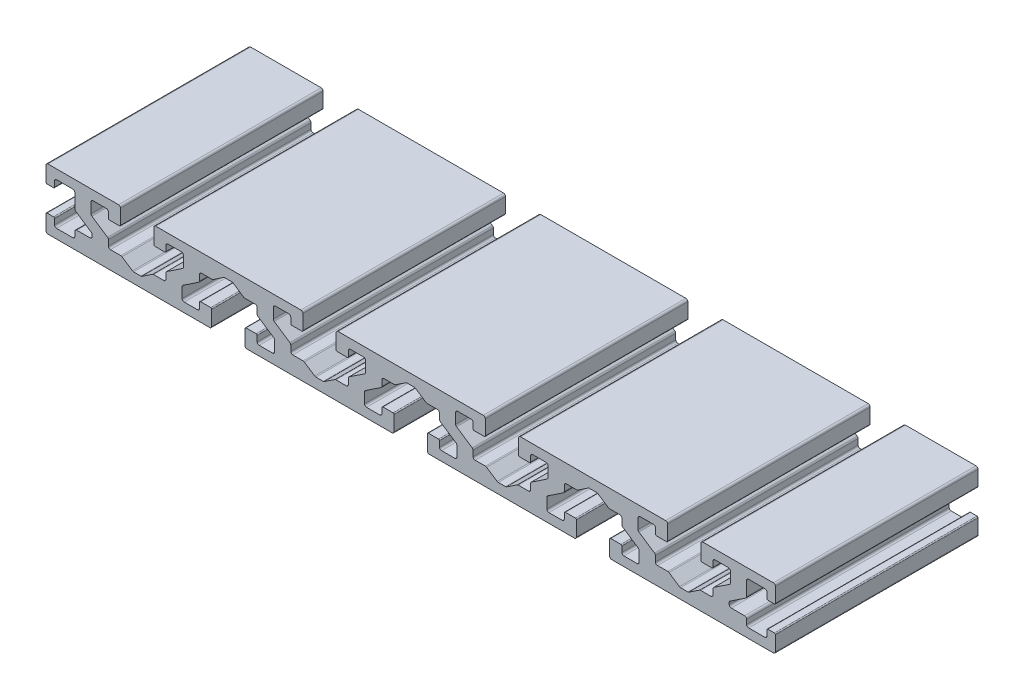
from build123d import *

# Parameters (mm, degrees)
BOSS_EXTRUDE1_DEPTH = 50


with BuildPart() as part:
    # Sketch1 → Boss-Extrude1 (new body)
    with BuildSketch(Plane.XY):
        with BuildLine():
            Line((0.5, 0), (40.4, 0))
            ThreePointArc((40.4, 0), (40.753553391, 0.146446609), (40.9, 0.5))
            Line((40.9, 0.5), (40.9, 4.15))
            ThreePointArc((40.9, 4.15), (40.826776695, 4.326776695), (40.65, 4.4))
            Line((40.65, 4.4), (38.15, 4.4))
            ThreePointArc((38.15, 4.4), (37.973223305, 4.326776695), (37.9, 4.15))
            Line((37.9, 4.15), (37.9, 2.8))
            ThreePointArc((37.9, 2.8), (37.753553391, 2.446446609), (37.4, 2.3))
            Line((37.4, 2.3), (34.1, 2.3))
            ThreePointArc((34.1, 2.3), (33.746446609, 2.446446609), (33.6, 2.8))
            Line((33.6, 2.8), (33.6, 5.329632483))
            ThreePointArc((33.6, 5.329632483), (33.659162701, 5.565561446), (33.822649902, 5.74565763))
            Line((33.822649902, 5.74565763), (37.677350098, 8.315457761))
            ThreePointArc((37.677350098, 8.315457761), (37.840837299, 8.495553945), (37.9, 8.731482908))
            Line((37.9, 8.731482908), (37.9, 10.1))
            ThreePointArc((37.9, 10.1), (38.046446609, 10.453553391), (38.4, 10.6))
            Line((38.4, 10.6), (40.952775638, 10.6))
            ThreePointArc((40.952775638, 10.6), (41.097667712, 10.621453987), (41.230125736, 10.683974853))
            Line((41.230125736, 10.683974853), (43.828201177, 12.416025147))
            ThreePointArc((43.828201177, 12.416025147), (43.960659201, 12.478546013), (44.105551275, 12.5))
            Line((44.105551275, 12.5), (45.894448725, 12.5))
            ThreePointArc((45.894448725, 12.5), (46.039340799, 12.478546013), (46.171798823, 12.416025147))
            Line((46.171798823, 12.416025147), (48.769874264, 10.683974853))
            ThreePointArc((48.769874264, 10.683974853), (48.902332288, 10.621453987), (49.047224362, 10.6))
            Line((49.047224362, 10.6), (51.6, 10.6))
            ThreePointArc((51.6, 10.6), (51.953553391, 10.453553391), (52.1, 10.1))
            Line((52.1, 10.1), (52.1, 8.731482908))
            ThreePointArc((52.1, 8.731482908), (52.159162701, 8.495553945), (52.322649902, 8.315457761))
            Line((52.322649902, 8.315457761), (56.177350098, 5.74565763))
            ThreePointArc((56.177350098, 5.74565763), (56.340837299, 5.565561446), (56.4, 5.329632483))
            Line((56.4, 5.329632483), (56.4, 2.8))
            ThreePointArc((56.4, 2.8), (56.253553391, 2.446446609), (55.9, 2.3))
            Line((55.9, 2.3), (52.6, 2.3))
            ThreePointArc((52.6, 2.3), (52.246446609, 2.446446609), (52.1, 2.8))
            Line((52.1, 2.8), (52.1, 4.15))
            ThreePointArc((52.1, 4.15), (52.026776695, 4.326776695), (51.85, 4.4))
            Line((51.85, 4.4), (49.35, 4.4))
            ThreePointArc((49.35, 4.4), (49.173223305, 4.326776695), (49.1, 4.15))
            Line((49.1, 4.15), (49.1, 0.5))
            ThreePointArc((49.1, 0.5), (49.246446609, 0.146446609), (49.6, 0))
            Line((49.6, 0), (85.4, 0))
            ThreePointArc((85.4, 0), (85.753553391, 0.146446609), (85.9, 0.5))
            Line((85.9, 0.5), (85.9, 4.15))
            ThreePointArc((85.9, 4.15), (85.826776695, 4.326776695), (85.65, 4.4))
            Line((85.65, 4.4), (83.15, 4.4))
            ThreePointArc((83.15, 4.4), (82.973223305, 4.326776695), (82.9, 4.15))
            Line((82.9, 4.15), (82.9, 2.8))
            ThreePointArc((82.9, 2.8), (82.753553391, 2.446446609), (82.4, 2.3))
            Line((82.4, 2.3), (79.1, 2.3))
            ThreePointArc((79.1, 2.3), (78.746446609, 2.446446609), (78.6, 2.8))
            Line((78.6, 2.8), (78.6, 5.329632483))
            ThreePointArc((78.6, 5.329632483), (78.659162701, 5.565561446), (78.822649902, 5.74565763))
            Line((78.822649902, 5.74565763), (82.677350098, 8.315457761))
            ThreePointArc((82.677350098, 8.315457761), (82.840837299, 8.495553945), (82.9, 8.731482908))
            Line((82.9, 8.731482908), (82.9, 10.1))
            ThreePointArc((82.9, 10.1), (83.046446609, 10.453553391), (83.4, 10.6))
            Line((83.4, 10.6), (85.952775638, 10.6))
            ThreePointArc((85.952775638, 10.6), (86.097667712, 10.621453987), (86.230125736, 10.683974853))
            Line((86.230125736, 10.683974853), (88.828201177, 12.416025147))
            ThreePointArc((88.828201177, 12.416025147), (88.960659201, 12.478546013), (89.105551275, 12.5))
            Line((89.105551275, 12.5), (90.894448725, 12.5))
            ThreePointArc((90.894448725, 12.5), (91.039340799, 12.478546013), (91.171798823, 12.416025147))
            Line((91.171798823, 12.416025147), (93.769874264, 10.683974853))
            ThreePointArc((93.769874264, 10.683974853), (93.902332288, 10.621453987), (94.047224362, 10.6))
            Line((94.047224362, 10.6), (96.6, 10.6))
            ThreePointArc((96.6, 10.6), (96.953553391, 10.453553391), (97.1, 10.1))
            Line((97.1, 10.1), (97.1, 8.731482908))
            ThreePointArc((97.1, 8.731482908), (97.159162701, 8.495553945), (97.322649902, 8.315457761))
            Line((97.322649902, 8.315457761), (101.177350098, 5.74565763))
            ThreePointArc((101.177350098, 5.74565763), (101.340837299, 5.565561446), (101.4, 5.329632483))
            Line((101.4, 5.329632483), (101.4, 2.8))
            ThreePointArc((101.4, 2.8), (101.253553391, 2.446446609), (100.9, 2.3))
            Line((100.9, 2.3), (97.6, 2.3))
            ThreePointArc((97.6, 2.3), (97.246446609, 2.446446609), (97.1, 2.8))
            Line((97.1, 2.8), (97.1, 4.15))
            ThreePointArc((97.1, 4.15), (97.026776695, 4.326776695), (96.85, 4.4))
            Line((96.85, 4.4), (94.35, 4.4))
            ThreePointArc((94.35, 4.4), (94.173223305, 4.326776695), (94.1, 4.15))
            Line((94.1, 4.15), (94.1, 0.5))
            ThreePointArc((94.1, 0.5), (94.246446609, 0.146446609), (94.6, 0))
            Line((94.6, 0), (130.4, 0))
            ThreePointArc((130.4, 0), (130.753553391, 0.146446609), (130.9, 0.5))
            Line((130.9, 0.5), (130.9, 4.15))
            ThreePointArc((130.9, 4.15), (130.826776695, 4.326776695), (130.65, 4.4))
            Line((130.65, 4.4), (128.15, 4.4))
            ThreePointArc((128.15, 4.4), (127.973223305, 4.326776695), (127.9, 4.15))
            Line((127.9, 4.15), (127.9, 2.8))
            ThreePointArc((127.9, 2.8), (127.753553391, 2.446446609), (127.4, 2.3))
            Line((127.4, 2.3), (124.1, 2.3))
            ThreePointArc((124.1, 2.3), (123.746446609, 2.446446609), (123.6, 2.8))
            Line((123.6, 2.8), (123.6, 5.329632483))
            ThreePointArc((123.6, 5.329632483), (123.659162701, 5.565561446), (123.822649902, 5.74565763))
            Line((123.822649902, 5.74565763), (127.677350098, 8.315457761))
            ThreePointArc((127.677350098, 8.315457761), (127.840837299, 8.495553945), (127.9, 8.731482908))
            Line((127.9, 8.731482908), (127.9, 10.1))
            ThreePointArc((127.9, 10.1), (128.046446609, 10.453553391), (128.4, 10.6))
            Line((128.4, 10.6), (130.952775638, 10.6))
            ThreePointArc((130.952775638, 10.6), (131.097667712, 10.621453987), (131.230125736, 10.683974853))
            Line((131.230125736, 10.683974853), (133.828201177, 12.416025147))
            ThreePointArc((133.828201177, 12.416025147), (133.960659201, 12.478546013), (134.105551275, 12.5))
            Line((134.105551275, 12.5), (135.894448725, 12.5))
            ThreePointArc((135.894448725, 12.5), (136.039340799, 12.478546013), (136.171798823, 12.416025147))
            Line((136.171798823, 12.416025147), (138.769874264, 10.683974853))
            ThreePointArc((138.769874264, 10.683974853), (138.902332288, 10.621453987), (139.047224362, 10.6))
            Line((139.047224362, 10.6), (141.6, 10.6))
            ThreePointArc((141.6, 10.6), (141.953553391, 10.453553391), (142.1, 10.1))
            Line((142.1, 10.1), (142.1, 8.731482908))
            ThreePointArc((142.1, 8.731482908), (142.159162701, 8.495553945), (142.322649902, 8.315457761))
            Line((142.322649902, 8.315457761), (146.177350098, 5.74565763))
            ThreePointArc((146.177350098, 5.74565763), (146.340837299, 5.565561446), (146.4, 5.329632483))
            Line((146.4, 5.329632483), (146.4, 2.8))
            ThreePointArc((146.4, 2.8), (146.253553391, 2.446446609), (145.9, 2.3))
            Line((145.9, 2.3), (142.6, 2.3))
            ThreePointArc((142.6, 2.3), (142.246446609, 2.446446609), (142.1, 2.8))
            Line((142.1, 2.8), (142.1, 4.15))
            ThreePointArc((142.1, 4.15), (142.026776695, 4.326776695), (141.85, 4.4))
            Line((141.85, 4.4), (139.35, 4.4))
            ThreePointArc((139.35, 4.4), (139.173223305, 4.326776695), (139.1, 4.15))
            Line((139.1, 4.15), (139.1, 0.5))
            ThreePointArc((139.1, 0.5), (139.246446609, 0.146446609), (139.6, 0))
            Line((139.6, 0), (179.5, 0))
            ThreePointArc((179.5, 0), (179.853553391, 0.146446609), (180, 0.5))
            Line((180, 0.5), (180, 4.15))
            ThreePointArc((180, 4.15), (179.926776695, 4.326776695), (179.75, 4.4))
            Line((179.75, 4.4), (178.15, 4.4))
            ThreePointArc((178.15, 4.4), (177.973223305, 4.326776695), (177.9, 4.15))
            Line((177.9, 4.15), (177.9, 2.8))
            ThreePointArc((177.9, 2.8), (177.753553391, 2.446446609), (177.4, 2.3))
            Line((177.4, 2.3), (173.4, 2.3))
            ThreePointArc((173.4, 2.3), (173.046446609, 2.446446609), (172.9, 2.8))
            Line((172.9, 2.8), (172.9, 3.9))
            ThreePointArc((172.9, 3.9), (172.753553391, 4.253553391), (172.4, 4.4))
            Line((172.4, 4.4), (169.1, 4.4))
            ThreePointArc((169.1, 4.4), (168.746446609, 4.546446609), (168.6, 4.9))
            Line((168.6, 4.9), (168.6, 5.329632483))
            ThreePointArc((168.6, 5.329632483), (168.659162701, 5.565561446), (168.822649902, 5.74565763))
            Line((168.822649902, 5.74565763), (172.677350098, 8.315457761))
            ThreePointArc((172.677350098, 8.315457761), (172.840837299, 8.495553945), (172.9, 8.731482908))
            Line((172.9, 8.731482908), (172.9, 12.2))
            ThreePointArc((172.9, 12.2), (173.046446609, 12.553553391), (173.4, 12.7))
            Line((173.4, 12.7), (177.4, 12.7))
            ThreePointArc((177.4, 12.7), (177.753553391, 12.553553391), (177.9, 12.2))
            Line((177.9, 12.2), (177.9, 10.85))
            ThreePointArc((177.9, 10.85), (177.973223305, 10.673223305), (178.15, 10.6))
            Line((178.15, 10.6), (179.75, 10.6))
            ThreePointArc((179.75, 10.6), (179.926776695, 10.673223305), (180, 10.85))
            Line((180, 10.85), (180, 14.5))
            ThreePointArc((180, 14.5), (179.853553391, 14.853553391), (179.5, 15))
            Line((179.5, 15), (162.1, 15))
            ThreePointArc((162.1, 15), (161.746446609, 14.853553391), (161.6, 14.5))
            Line((161.6, 14.5), (161.6, 10.85))
            ThreePointArc((161.6, 10.85), (161.673223305, 10.673223305), (161.85, 10.6))
            Line((161.85, 10.6), (164.35, 10.6))
            ThreePointArc((164.35, 10.6), (164.526776695, 10.673223305), (164.6, 10.85))
            Line((164.6, 10.85), (164.6, 12.2))
            ThreePointArc((164.6, 12.2), (164.746446609, 12.553553391), (165.1, 12.7))
            Line((165.1, 12.7), (168.4, 12.7))
            ThreePointArc((168.4, 12.7), (168.753553391, 12.553553391), (168.9, 12.2))
            Line((168.9, 12.2), (168.9, 9.670367517))
            ThreePointArc((168.9, 9.670367517), (168.840837299, 9.434438554), (168.677350098, 9.25434237))
            Line((168.677350098, 9.25434237), (164.822649902, 6.684542239))
            ThreePointArc((164.822649902, 6.684542239), (164.659162701, 6.504446055), (164.6, 6.268517092))
            Line((164.6, 6.268517092), (164.6, 4.9))
            ThreePointArc((164.6, 4.9), (164.453553391, 4.546446609), (164.1, 4.4))
            Line((164.1, 4.4), (161.547224362, 4.4))
            ThreePointArc((161.547224362, 4.4), (161.402332288, 4.378546013), (161.269874264, 4.316025147))
            Line((161.269874264, 4.316025147), (158.671798823, 2.583974853))
            ThreePointArc((158.671798823, 2.583974853), (158.539340799, 2.521453987), (158.394448725, 2.5))
            Line((158.394448725, 2.5), (156.605551275, 2.5))
            ThreePointArc((156.605551275, 2.5), (156.460659201, 2.521453987), (156.328201177, 2.583974853))
            Line((156.328201177, 2.583974853), (153.730125736, 4.316025147))
            ThreePointArc((153.730125736, 4.316025147), (153.597667712, 4.378546013), (153.452775638, 4.4))
            Line((153.452775638, 4.4), (150.9, 4.4))
            ThreePointArc((150.9, 4.4), (150.546446609, 4.546446609), (150.4, 4.9))
            Line((150.4, 4.9), (150.4, 6.268517092))
            ThreePointArc((150.4, 6.268517092), (150.340837299, 6.504446055), (150.177350098, 6.684542239))
            Line((150.177350098, 6.684542239), (146.322649902, 9.25434237))
            ThreePointArc((146.322649902, 9.25434237), (146.159162701, 9.434438554), (146.1, 9.670367517))
            Line((146.1, 9.670367517), (146.1, 12.2))
            ThreePointArc((146.1, 12.2), (146.246446609, 12.553553391), (146.6, 12.7))
            Line((146.6, 12.7), (149.9, 12.7))
            ThreePointArc((149.9, 12.7), (150.253553391, 12.553553391), (150.4, 12.2))
            Line((150.4, 12.2), (150.4, 10.85))
            ThreePointArc((150.4, 10.85), (150.473223305, 10.673223305), (150.65, 10.6))
            Line((150.65, 10.6), (153.15, 10.6))
            ThreePointArc((153.15, 10.6), (153.326776695, 10.673223305), (153.4, 10.85))
            Line((153.4, 10.85), (153.4, 14.5))
            ThreePointArc((153.4, 14.5), (153.253553391, 14.853553391), (152.9, 15))
            Line((152.9, 15), (117.1, 15))
            ThreePointArc((117.1, 15), (116.746446609, 14.853553391), (116.6, 14.5))
            Line((116.6, 14.5), (116.6, 10.85))
            ThreePointArc((116.6, 10.85), (116.673223305, 10.673223305), (116.85, 10.6))
            Line((116.85, 10.6), (119.35, 10.6))
            ThreePointArc((119.35, 10.6), (119.526776695, 10.673223305), (119.6, 10.85))
            Line((119.6, 10.85), (119.6, 12.2))
            ThreePointArc((119.6, 12.2), (119.746446609, 12.553553391), (120.1, 12.7))
            Line((120.1, 12.7), (123.4, 12.7))
            ThreePointArc((123.4, 12.7), (123.753553391, 12.553553391), (123.9, 12.2))
            Line((123.9, 12.2), (123.9, 9.670367517))
            ThreePointArc((123.9, 9.670367517), (123.840837299, 9.434438554), (123.677350098, 9.25434237))
            Line((123.677350098, 9.25434237), (119.822649902, 6.684542239))
            ThreePointArc((119.822649902, 6.684542239), (119.659162701, 6.504446055), (119.6, 6.268517092))
            Line((119.6, 6.268517092), (119.6, 4.9))
            ThreePointArc((119.6, 4.9), (119.453553391, 4.546446609), (119.1, 4.4))
            Line((119.1, 4.4), (116.547224362, 4.4))
            ThreePointArc((116.547224362, 4.4), (116.402332288, 4.378546013), (116.269874264, 4.316025147))
            Line((116.269874264, 4.316025147), (113.671798823, 2.583974853))
            ThreePointArc((113.671798823, 2.583974853), (113.539340799, 2.521453987), (113.394448725, 2.5))
            Line((113.394448725, 2.5), (111.605551275, 2.5))
            ThreePointArc((111.605551275, 2.5), (111.460659201, 2.521453987), (111.328201177, 2.583974853))
            Line((111.328201177, 2.583974853), (108.730125736, 4.316025147))
            ThreePointArc((108.730125736, 4.316025147), (108.597667712, 4.378546013), (108.452775638, 4.4))
            Line((108.452775638, 4.4), (105.9, 4.4))
            ThreePointArc((105.9, 4.4), (105.546446609, 4.546446609), (105.4, 4.9))
            Line((105.4, 4.9), (105.4, 6.268517092))
            ThreePointArc((105.4, 6.268517092), (105.340837299, 6.504446055), (105.177350098, 6.684542239))
            Line((105.177350098, 6.684542239), (101.322649902, 9.25434237))
            ThreePointArc((101.322649902, 9.25434237), (101.159162701, 9.434438554), (101.1, 9.670367517))
            Line((101.1, 9.670367517), (101.1, 12.2))
            ThreePointArc((101.1, 12.2), (101.246446609, 12.553553391), (101.6, 12.7))
            Line((101.6, 12.7), (104.9, 12.7))
            ThreePointArc((104.9, 12.7), (105.253553391, 12.553553391), (105.4, 12.2))
            Line((105.4, 12.2), (105.4, 10.85))
            ThreePointArc((105.4, 10.85), (105.473223305, 10.673223305), (105.65, 10.6))
            Line((105.65, 10.6), (108.15, 10.6))
            ThreePointArc((108.15, 10.6), (108.326776695, 10.673223305), (108.4, 10.85))
            Line((108.4, 10.85), (108.4, 14.5))
            ThreePointArc((108.4, 14.5), (108.253553391, 14.853553391), (107.9, 15))
            Line((107.9, 15), (72.1, 15))
            ThreePointArc((72.1, 15), (71.746446609, 14.853553391), (71.6, 14.5))
            Line((71.6, 14.5), (71.6, 10.85))
            ThreePointArc((71.6, 10.85), (71.673223305, 10.673223305), (71.85, 10.6))
            Line((71.85, 10.6), (74.35, 10.6))
            ThreePointArc((74.35, 10.6), (74.526776695, 10.673223305), (74.6, 10.85))
            Line((74.6, 10.85), (74.6, 12.2))
            ThreePointArc((74.6, 12.2), (74.746446609, 12.553553391), (75.1, 12.7))
            Line((75.1, 12.7), (78.4, 12.7))
            ThreePointArc((78.4, 12.7), (78.753553391, 12.553553391), (78.9, 12.2))
            Line((78.9, 12.2), (78.9, 9.670367517))
            ThreePointArc((78.9, 9.670367517), (78.840837299, 9.434438554), (78.677350098, 9.25434237))
            Line((78.677350098, 9.25434237), (74.822649902, 6.684542239))
            ThreePointArc((74.822649902, 6.684542239), (74.659162701, 6.504446055), (74.6, 6.268517092))
            Line((74.6, 6.268517092), (74.6, 4.9))
            ThreePointArc((74.6, 4.9), (74.453553391, 4.546446609), (74.1, 4.4))
            Line((74.1, 4.4), (71.547224362, 4.4))
            ThreePointArc((71.547224362, 4.4), (71.402332288, 4.378546013), (71.269874264, 4.316025147))
            Line((71.269874264, 4.316025147), (68.671798823, 2.583974853))
            ThreePointArc((68.671798823, 2.583974853), (68.539340799, 2.521453987), (68.394448725, 2.5))
            Line((68.394448725, 2.5), (66.605551275, 2.5))
            ThreePointArc((66.605551275, 2.5), (66.460659201, 2.521453987), (66.328201177, 2.583974853))
            Line((66.328201177, 2.583974853), (63.730125736, 4.316025147))
            ThreePointArc((63.730125736, 4.316025147), (63.597667712, 4.378546013), (63.452775638, 4.4))
            Line((63.452775638, 4.4), (60.9, 4.4))
            ThreePointArc((60.9, 4.4), (60.546446609, 4.546446609), (60.4, 4.9))
            Line((60.4, 4.9), (60.4, 6.268517092))
            ThreePointArc((60.4, 6.268517092), (60.340837299, 6.504446055), (60.177350098, 6.684542239))
            Line((60.177350098, 6.684542239), (56.322649902, 9.25434237))
            ThreePointArc((56.322649902, 9.25434237), (56.159162701, 9.434438554), (56.1, 9.670367517))
            Line((56.1, 9.670367517), (56.1, 12.2))
            ThreePointArc((56.1, 12.2), (56.246446609, 12.553553391), (56.6, 12.7))
            Line((56.6, 12.7), (59.9, 12.7))
            ThreePointArc((59.9, 12.7), (60.253553391, 12.553553391), (60.4, 12.2))
            Line((60.4, 12.2), (60.4, 10.85))
            ThreePointArc((60.4, 10.85), (60.473223305, 10.673223305), (60.65, 10.6))
            Line((60.65, 10.6), (63.15, 10.6))
            ThreePointArc((63.15, 10.6), (63.326776695, 10.673223305), (63.4, 10.85))
            Line((63.4, 10.85), (63.4, 14.5))
            ThreePointArc((63.4, 14.5), (63.253553391, 14.853553391), (62.9, 15))
            Line((62.9, 15), (27.1, 15))
            ThreePointArc((27.1, 15), (26.746446609, 14.853553391), (26.6, 14.5))
            Line((26.6, 14.5), (26.6, 10.85))
            ThreePointArc((26.6, 10.85), (26.673223305, 10.673223305), (26.85, 10.6))
            Line((26.85, 10.6), (29.35, 10.6))
            ThreePointArc((29.35, 10.6), (29.526776695, 10.673223305), (29.6, 10.85))
            Line((29.6, 10.85), (29.6, 12.2))
            ThreePointArc((29.6, 12.2), (29.746446609, 12.553553391), (30.1, 12.7))
            Line((30.1, 12.7), (33.4, 12.7))
            ThreePointArc((33.4, 12.7), (33.753553391, 12.553553391), (33.9, 12.2))
            Line((33.9, 12.2), (33.9, 9.670367517))
            ThreePointArc((33.9, 9.670367517), (33.840837299, 9.434438554), (33.677350098, 9.25434237))
            Line((33.677350098, 9.25434237), (29.822649902, 6.684542239))
            ThreePointArc((29.822649902, 6.684542239), (29.659162701, 6.504446055), (29.6, 6.268517092))
            Line((29.6, 6.268517092), (29.6, 4.9))
            ThreePointArc((29.6, 4.9), (29.453553391, 4.546446609), (29.1, 4.4))
            Line((29.1, 4.4), (26.547224362, 4.4))
            ThreePointArc((26.547224362, 4.4), (26.402332288, 4.378546013), (26.269874264, 4.316025147))
            Line((26.269874264, 4.316025147), (23.671798823, 2.583974853))
            ThreePointArc((23.671798823, 2.583974853), (23.539340799, 2.521453987), (23.394448725, 2.5))
            Line((23.394448725, 2.5), (21.605551275, 2.5))
            ThreePointArc((21.605551275, 2.5), (21.460659201, 2.521453987), (21.328201177, 2.583974853))
            Line((21.328201177, 2.583974853), (18.730125736, 4.316025147))
            ThreePointArc((18.730125736, 4.316025147), (18.597667712, 4.378546013), (18.452775638, 4.4))
            Line((18.452775638, 4.4), (15.9, 4.4))
            ThreePointArc((15.9, 4.4), (15.546446609, 4.546446609), (15.4, 4.9))
            Line((15.4, 4.9), (15.4, 6.268517092))
            ThreePointArc((15.4, 6.268517092), (15.340837299, 6.504446055), (15.177350098, 6.684542239))
            Line((15.177350098, 6.684542239), (11.322649902, 9.25434237))
            ThreePointArc((11.322649902, 9.25434237), (11.159162701, 9.434438554), (11.1, 9.670367517))
            Line((11.1, 9.670367517), (11.1, 12.2))
            ThreePointArc((11.1, 12.2), (11.246446609, 12.553553391), (11.6, 12.7))
            Line((11.6, 12.7), (14.9, 12.7))
            ThreePointArc((14.9, 12.7), (15.253553391, 12.553553391), (15.4, 12.2))
            Line((15.4, 12.2), (15.4, 10.85))
            ThreePointArc((15.4, 10.85), (15.473223305, 10.673223305), (15.65, 10.6))
            Line((15.65, 10.6), (18.15, 10.6))
            ThreePointArc((18.15, 10.6), (18.326776695, 10.673223305), (18.4, 10.85))
            Line((18.4, 10.85), (18.4, 14.5))
            ThreePointArc((18.4, 14.5), (18.253553391, 14.853553391), (17.9, 15))
            Line((17.9, 15), (0.5, 15))
            ThreePointArc((0.5, 15), (0.146446609, 14.853553391), (0, 14.5))
            Line((0, 14.5), (0, 10.85))
            ThreePointArc((0, 10.85), (0.073223305, 10.673223305), (0.25, 10.6))
            Line((0.25, 10.6), (1.85, 10.6))
            ThreePointArc((1.85, 10.6), (2.026776695, 10.673223305), (2.1, 10.85))
            Line((2.1, 10.85), (2.1, 12.2))
            ThreePointArc((2.1, 12.2), (2.246446609, 12.553553391), (2.6, 12.7))
            Line((2.6, 12.7), (6.6, 12.7))
            ThreePointArc((6.6, 12.7), (6.953553391, 12.553553391), (7.1, 12.2))
            Line((7.1, 12.2), (7.1, 8.731482908))
            ThreePointArc((7.1, 8.731482908), (7.159162701, 8.495553945), (7.322649902, 8.315457761))
            Line((7.322649902, 8.315457761), (11.177350098, 5.74565763))
            ThreePointArc((11.177350098, 5.74565763), (11.340837299, 5.565561446), (11.4, 5.329632483))
            Line((11.4, 5.329632483), (11.4, 4.9))
            ThreePointArc((11.4, 4.9), (11.253553391, 4.546446609), (10.9, 4.4))
            Line((10.9, 4.4), (7.6, 4.4))
            ThreePointArc((7.6, 4.4), (7.246446609, 4.253553391), (7.1, 3.9))
            Line((7.1, 3.9), (7.1, 2.8))
            ThreePointArc((7.1, 2.8), (6.953553391, 2.446446609), (6.6, 2.3))
            Line((6.6, 2.3), (2.6, 2.3))
            ThreePointArc((2.6, 2.3), (2.246446609, 2.446446609), (2.1, 2.8))
            Line((2.1, 2.8), (2.1, 4.15))
            ThreePointArc((2.1, 4.15), (2.026776695, 4.326776695), (1.85, 4.4))
            Line((1.85, 4.4), (0.25, 4.4))
            ThreePointArc((0.25, 4.4), (0.073223305, 4.326776695), (0, 4.15))
            Line((0, 4.15), (0, 0.5))
            ThreePointArc((0, 0.5), (0.146446609, 0.146446609), (0.5, 0))
        make_face()
    extrude(amount=BOSS_EXTRUDE1_DEPTH)


solid = part.part
